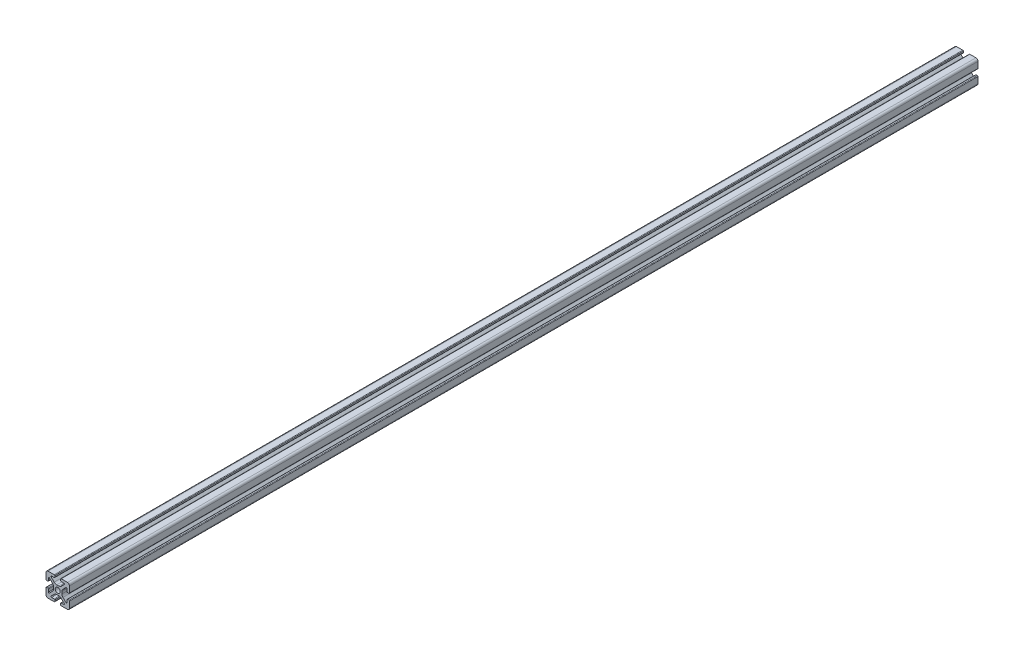
from build123d import *

# Parameters (mm, degrees)
BOSS_EXTRUDE1_DEPTH = 387.7


with BuildPart() as part:
    # Sketch4 → Boss-Extrude1 (new body, symmetric)
    with BuildSketch(Plane.XY):
        with BuildLine():
            Line((3, -10), (8.25, -10))
            ThreePointArc((8.25, -10), (9.487436867, -9.487436867), (10, -8.25))
            Line((10, -8.25), (10, -3))
            ThreePointArc((10, -3), (9.853553391, -2.646446609), (9.5, -2.5))
            Line((9.5, -2.5), (8.424621202, -2.5))
            ThreePointArc((8.424621202, -2.5), (8.071067812, -2.646446609), (7.924621202, -3))
            Line((7.924621202, -3), (7.924621202, -5.25))
            ThreePointArc((7.924621202, -5.25), (7.615962919, -5.711939766), (7.071067812, -5.603553391))
            Line((7.071067812, -5.603553391), (4.478679656, -3.011165235))
            ThreePointArc((4.478679656, -3.011165235), (3.828361402, -2.037895189), (3.6, -0.889844892))
            Line((3.6, -0.889844892), (3.6, 0))
            Line((3.6, 0), (2.15, 0))
            ThreePointArc((2.15, 0), (1.52027958, -1.52027958), (0, -2.15))
            Line((0, -2.15), (0, -3.6))
            Line((0, -3.6), (0.889844892, -3.6))
            ThreePointArc((0.889844892, -3.6), (2.037895189, -3.828361402), (3.011165235, -4.478679656))
            Line((3.011165235, -4.478679656), (5.603553391, -7.071067812))
            ThreePointArc((5.603553391, -7.071067812), (5.711939766, -7.615962919), (5.25, -7.924621202))
            Line((5.25, -7.924621202), (3, -7.924621202))
            ThreePointArc((3, -7.924621202), (2.646446609, -8.071067812), (2.5, -8.424621202))
            Line((2.5, -8.424621202), (2.5, -9.5))
            ThreePointArc((2.5, -9.5), (2.646446609, -9.853553391), (3, -10))
        make_face()
    extrude(amount=BOSS_EXTRUDE1_DEPTH, both=True)

    # Mirror1: part across plane


with BuildPart() as part_1:
    add(part.part)
    add(part.part.mirror(Plane(origin=(0, 0, 0), x_dir=(0, 0, 1), z_dir=(1, 0, 0))))

    # Mirror2: part across plane


with BuildPart() as part_2:
    add(part_1.part)
    add(part_1.part.mirror(Plane.ZX))


solid = part_2.part
